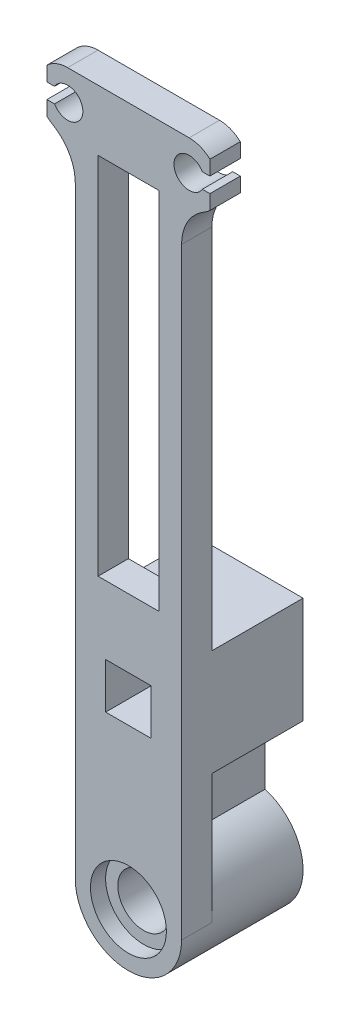
from build123d import *

# Parameters (mm, degrees)
SKETCH_1_R          = 1.7
SKETCH_1_R_2        = 1
SKETCH_1_W          = 4
SKETCH_1_H          = 24
SKETCH_1_W_2        = 3
SKETCH_1_H_2        = 3
EXTRUDE_1_DEPTH     = 2
SKETCH_2_W          = 3
SKETCH_2_H          = 3
SKETCH_2_R          = 1.7
EXTRUDE_2_DEPTH     = 6
FILLET_2_R          = 3
SKETCH_4_R          = 2.5
CUT_EXTRUDE_2_DEPTH = 1
SKETCH_5_R          = 2.5
CUT_EXTRUDE_3_DEPTH = 1
CUT_EXTRUDE_4_DEPTH = 10


with BuildPart() as part:
    # 草图1 → 凸台-拉伸1 (new body)
    with BuildSketch(Plane.XY):
        with BuildLine():
            Line((4, 46), (-4, 46))
            ThreePointArc((-4, 46), (-5.984059393, 43.747991415), (-3.5, 42.063508327))
            Line((-3.5, 42.063508327), (-3.5, 42))
            Line((-3.5, 42), (-3.5, 0))
            ThreePointArc((-3.5, 0), (0, -3.5), (3.5, 0))
            Line((3.5, 0), (3.5, 42))
            Line((3.5, 42), (3.5, 42.063508327))
            ThreePointArc((3.5, 42.063508327), (5.984059393, 43.747991415), (4, 46))
        make_face()
        Circle(SKETCH_1_R, mode=Mode.SUBTRACT)
        with Locations((-4, 44)):
            Circle(SKETCH_1_R_2, mode=Mode.SUBTRACT)
        with Locations((4, 44)):
            Circle(SKETCH_1_R_2, mode=Mode.SUBTRACT)
        with Locations((0, 30)):
            Rectangle(SKETCH_1_W, SKETCH_1_H, mode=Mode.SUBTRACT)
        with Locations((0, 12)):
            Rectangle(SKETCH_1_W_2, SKETCH_1_H_2, mode=Mode.SUBTRACT)
    extrude(amount=EXTRUDE_1_DEPTH)

    # 草图2 → 凸台-拉伸2 (add)
    with BuildSketch(Plane(origin=(0, 0, 0), x_dir=(-1, 0, 0), z_dir=(0, 0, -1))):
        Polygon((3.5, 15.5), (-3.5, 15.5), (-3.5, 8.5), (-1, 8.5), (1, 8.5), (3.5, 8.5), align=None)
        with Locations((0, 12)):
            Rectangle(SKETCH_2_W, SKETCH_2_H, mode=Mode.SUBTRACT)
        with BuildLine():
            Line((1, 8.5), (-1, 8.5))
            Line((-1, 8.5), (-1, 3.354101966))
            ThreePointArc((-1, 3.354101966), (0, 3.5), (1, 3.354101966))
            Line((1, 3.354101966), (1, 8.5))
        make_face()
        with BuildLine():
            ThreePointArc((-1, 3.354101966), (-2.80624304, 2.091650066), (-3.5, 0))
            ThreePointArc((-3.5, 0), (0, -3.5), (3.5, 0))
            ThreePointArc((3.5, 0), (2.80624304, 2.091650066), (1, 3.354101966))
            ThreePointArc((1, 3.354101966), (0, 3.5), (-1, 3.354101966))
        make_face()
        Circle(SKETCH_2_R, mode=Mode.SUBTRACT)
    extrude(amount=EXTRUDE_2_DEPTH)

    # 圆角2
    fillet_2_edges = [part.edges().sort_by_distance(p)[0] for p in [
        (3.5, 42.063508327, 1),
        (-3.5, 42.063508327, 1),
    ]]
    fillet(fillet_2_edges, radius=FILLET_2_R)

    # 草图4 → 切除-拉伸2 (cut)
    with BuildSketch(Plane.XY.offset(2)):
        Circle(SKETCH_4_R)
    extrude(amount=-CUT_EXTRUDE_2_DEPTH, mode=Mode.SUBTRACT)

    # 草图5 → 切除-拉伸3 (cut)
    with BuildSketch(Plane(origin=(0, 0, -6), x_dir=(-1, 0, 0), z_dir=(0, 0, -1))):
        Circle(SKETCH_5_R)
    extrude(amount=-CUT_EXTRUDE_3_DEPTH, mode=Mode.SUBTRACT)

    # 草图3 → 切除-拉伸4 (cut)
    with BuildSketch(Plane.XY.offset(2)):
        with BuildLine():
            Line((-5.366025404, 44.5), (-5.366025404, 43.5))
            Line((-5.366025404, 43.5), (-4.866025404, 43.5))
            ThreePointArc((-4.866025404, 43.5), (-5, 44), (-4.866025404, 44.5))
            Line((-4.866025404, 44.5), (-5.366025404, 44.5))
        make_face()
        with BuildLine():
            ThreePointArc((-5.936491673, 44.5), (-6, 44), (-5.936491673, 43.5))
            Line((-5.936491673, 43.5), (-5.366025404, 43.5))
            Line((-5.366025404, 43.5), (-5.366025404, 44.5))
            Line((-5.366025404, 44.5), (-5.936491673, 44.5))
        make_face()
        with BuildLine():
            ThreePointArc((-5.366025404, 45.460812992), (-5.719722408, 45.021055747), (-5.936491673, 44.5))
            Line((-5.936491673, 44.5), (-5.366025404, 44.5))
            Line((-5.366025404, 44.5), (-5.366025404, 45.460812992))
        make_face()
        with BuildLine():
            Line((-5.366025404, 43.5), (-5.936491673, 43.5))
            ThreePointArc((-5.936491673, 43.5), (-5.719722408, 42.978944253), (-5.366025404, 42.539187008))
            Line((-5.366025404, 42.539187008), (-5.366025404, 43.5))
        make_face()
        with BuildLine():
            ThreePointArc((5.936491673, 43.5), (6, 44), (5.936491673, 44.5))
            Line((5.936491673, 44.5), (5.366025404, 44.5))
            Line((5.366025404, 44.5), (5.366025404, 43.5))
            Line((5.366025404, 43.5), (5.936491673, 43.5))
        make_face()
        with BuildLine():
            Line((5.366025404, 44.5), (5.936491673, 44.5))
            ThreePointArc((5.936491673, 44.5), (5.719722408, 45.021055747), (5.366025404, 45.460812992))
            Line((5.366025404, 45.460812992), (5.366025404, 44.5))
        make_face()
        with BuildLine():
            Line((5.366025404, 43.5), (5.366025404, 44.5))
            Line((5.366025404, 44.5), (4.866025404, 44.5))
            ThreePointArc((4.866025404, 44.5), (4.965925826, 44.258819045), (5, 44))
            ThreePointArc((5, 44), (4.965925826, 43.741180955), (4.866025404, 43.5))
            Line((4.866025404, 43.5), (5.366025404, 43.5))
        make_face()
        with BuildLine():
            ThreePointArc((5.366025404, 42.539187008), (5.719722408, 42.978944253), (5.936491673, 43.5))
            Line((5.936491673, 43.5), (5.366025404, 43.5))
            Line((5.366025404, 43.5), (5.366025404, 42.539187008))
        make_face()
    extrude(amount=-CUT_EXTRUDE_4_DEPTH, mode=Mode.SUBTRACT)


solid = part.part
